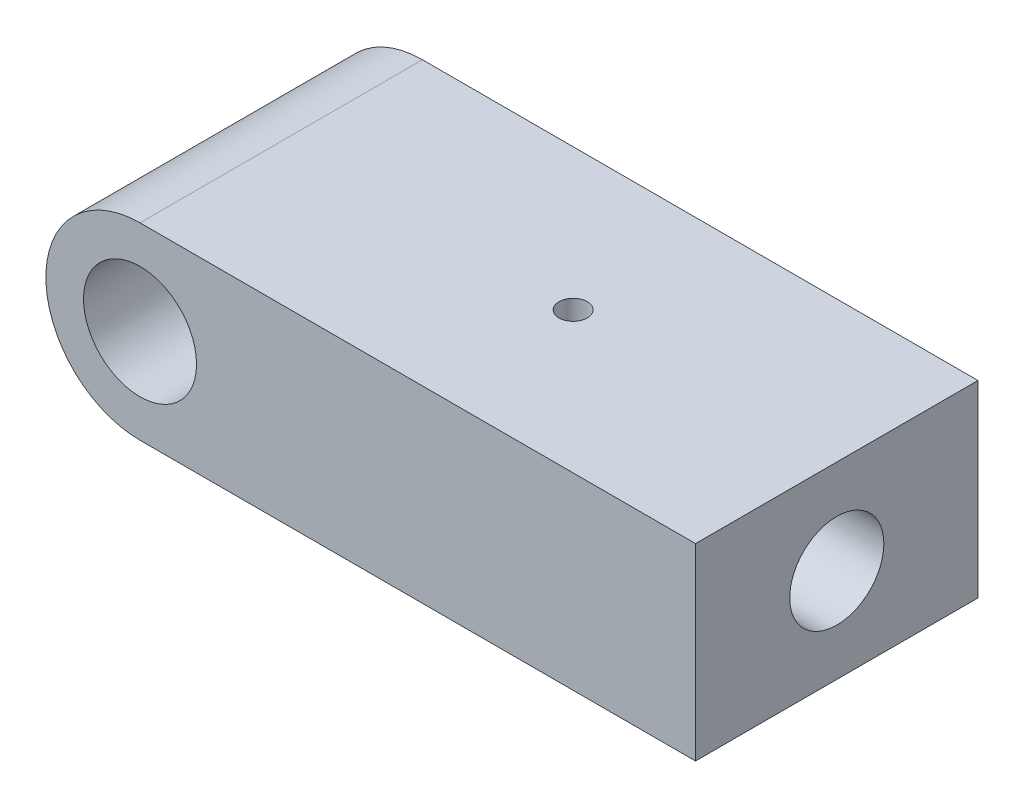
from build123d import *

# Parameters (mm, degrees)
ESQUISSE1_R                         = 6
BOSS_EXTRU_1_DEPTH                  = 15
DIAM_TRE_DU_PER_AGE_10_0_10_1_D     = 10
DIAM_TRE_DU_PER_AGE_10_0_10_1_DEPTH = 40
DIAM_TRE_DU_PER_AGE_10_0_10_1_TIP   = 3.004303095
DIAM_TRE_DU_PER_AGE_3_0_3_1_D       = 3
DIAM_TRE_DU_PER_AGE_3_0_3_1_DEPTH   = 10
DIAM_TRE_DU_PER_AGE_3_0_3_1_TIP     = 0.901290929
TROU_TARAUD_M41_D                   = 3.3
TROU_TARAUD_M41_DEPTH               = 11.5
TROU_TARAUD_M41_TIP                 = 0.991420021


with BuildPart() as part:
    # Esquisse1 → Boss.-Extru.1 (new body, symmetric)
    with BuildSketch(Plane.XY):
        with BuildLine():
            Line((0, -10), (59, -10))
            Line((59, -10), (59, 10))
            Line((59, 10), (0, 10))
            ThreePointArc((0, 10), (-10, 0), (0, -10))
        make_face()
        Circle(ESQUISSE1_R, mode=Mode.SUBTRACT)
    extrude(amount=BOSS_EXTRU_1_DEPTH, both=True)

    # Diamètre du perçage Ø10.0 (10)1
    with Locations(Plane(origin=(59, 0, 0), x_dir=(0, 0, -1), z_dir=(1, 0, 0))):
        with Locations((0, 0)):
            Hole(DIAM_TRE_DU_PER_AGE_10_0_10_1_D / 2, depth=DIAM_TRE_DU_PER_AGE_10_0_10_1_DEPTH)
            with Locations((0, 0, -(DIAM_TRE_DU_PER_AGE_10_0_10_1_DEPTH + DIAM_TRE_DU_PER_AGE_10_0_10_1_TIP / 2))):  # 118° drill point
                Cone(0, DIAM_TRE_DU_PER_AGE_10_0_10_1_D / 2, DIAM_TRE_DU_PER_AGE_10_0_10_1_TIP, mode=Mode.SUBTRACT)

    # Diamètre du perçage Ø3.0 (3)1
    with Locations(Plane(origin=(0, 10, 0), x_dir=(1, 0, 0), z_dir=(0, 1, 0))):
        with Locations((31, 0)):
            Hole(DIAM_TRE_DU_PER_AGE_3_0_3_1_D / 2, depth=DIAM_TRE_DU_PER_AGE_3_0_3_1_DEPTH)
            with Locations((0, 0, -(DIAM_TRE_DU_PER_AGE_3_0_3_1_DEPTH + DIAM_TRE_DU_PER_AGE_3_0_3_1_TIP / 2))):  # 118° drill point
                Cone(0, DIAM_TRE_DU_PER_AGE_3_0_3_1_D / 2, DIAM_TRE_DU_PER_AGE_3_0_3_1_TIP, mode=Mode.SUBTRACT)

    # Trou taraudé M41
    with Locations(Plane(origin=(0, -10, 0), x_dir=(-1, 0, 0), z_dir=(0, -1, 0))):
        with Locations((-40, 0), (-23, 0)):
            Hole(TROU_TARAUD_M41_D / 2, depth=TROU_TARAUD_M41_DEPTH)
            with Locations((0, 0, -(TROU_TARAUD_M41_DEPTH + TROU_TARAUD_M41_TIP / 2))):  # 118° drill point
                Cone(0, TROU_TARAUD_M41_D / 2, TROU_TARAUD_M41_TIP, mode=Mode.SUBTRACT)


solid = part.part
